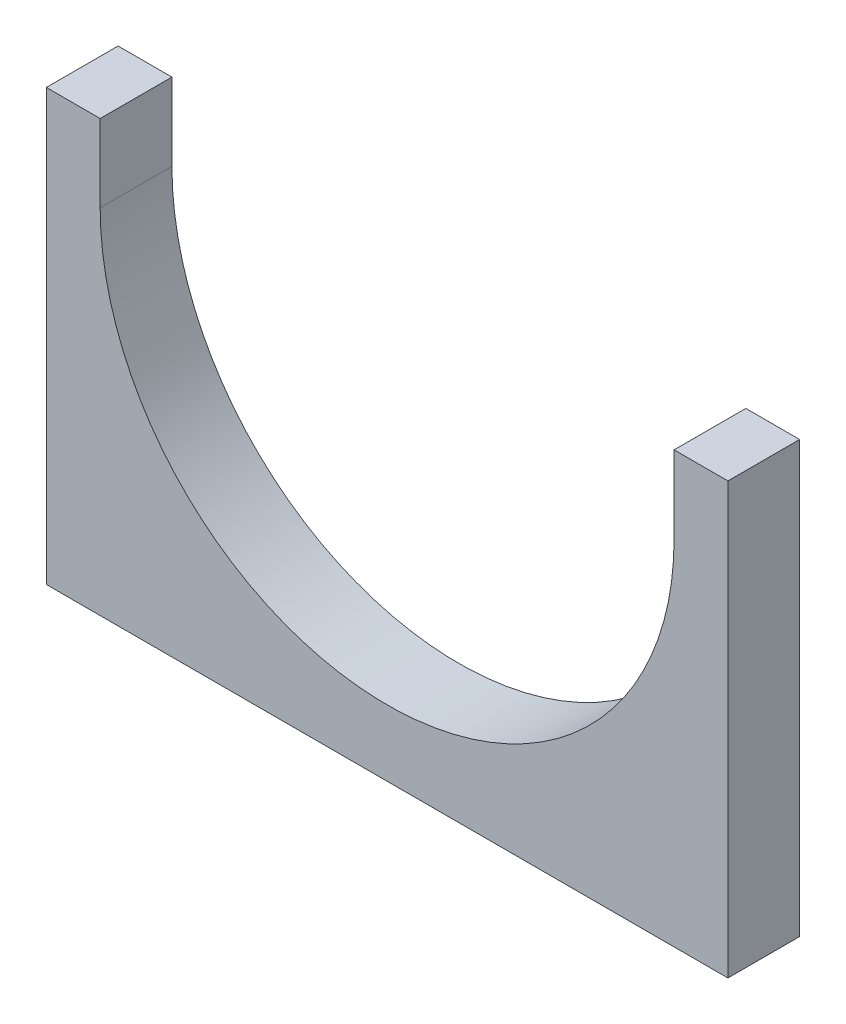
from build123d import *

# Parameters (mm, degrees)
BOSS_EXTRUDE1_DEPTH = 101.6


with BuildPart() as part:
    # Sketch1 → Boss-Extrude1 (new body)
    with BuildSketch(Plane.XY):
        with BuildLine():
            Line((76.2, 500), (76.2, 609.6))
            Line((76.2, 609.6), (0, 609.6))
            Line((0, 609.6), (0, 0))
            Line((0, 0), (965.1, 0))
            Line((965.1, 0), (965.1, 609.6))
            Line((965.1, 609.6), (888.9, 609.6))
            Line((888.9, 609.6), (888.9, 500))
            ThreePointArc((888.9, 500), (482.55, 93.65), (76.2, 500))
        make_face()
    extrude(amount=BOSS_EXTRUDE1_DEPTH)


solid = part.part
